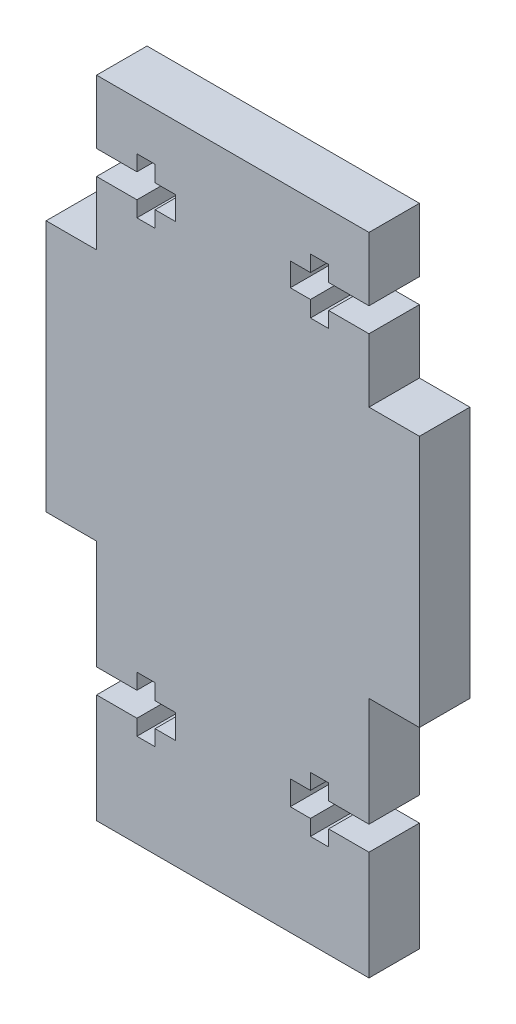
from build123d import *

# Parameters (mm, degrees)
BOSS_EXTRUDE1_DEPTH = 5
CUT_EXTRUDE2_DEPTH  = 6


with BuildPart() as part:
    # Sketch1 → Boss-Extrude1 (new body)
    with BuildSketch(Plane.XY):
        Polygon((-13.5, 0), (13.5, 0), (13.5, 24), (18.5, 24), (18.5, 49), (13.5, 49), (13.5, 64), (-13.5, 64), (-13.5, 49), (-18.5, 49), (-18.5, 24), (-13.5, 24), align=None)
    extrude(amount=BOSS_EXTRUDE1_DEPTH)

    # Sketch2 → Cut-Extrude2 (cut, through all)
    with BuildSketch(Plane.XY.offset(5)):
        Polygon((-13.5, 56.5), (-13.5, 57.7), (-9.5, 57.7), (-9.5, 59.25), (-7.7, 59.25), (-7.7, 57.654169795), (-5.7, 57.654169795), (-5.7, 55.345830205), (-7.7, 55.345830205), (-7.7, 53.75), (-9.5, 53.75), (-9.5, 55.3), (-13.5, 55.3), align=None)
        Polygon((13.5, 56.5), (13.5, 55.3), (9.5, 55.3), (9.5, 53.75), (7.7, 53.75), (7.7, 55.345830205), (5.7, 55.345830205), (5.7, 57.654169795), (7.7, 57.654169795), (7.7, 59.25), (9.5, 59.25), (9.5, 57.7), (13.5, 57.7), align=None)
        Polygon((-13.5, 10.8), (-13.5, 13.2), (-9.5, 13.2), (-9.5, 14.75), (-7.7, 14.75), (-7.7, 13.2), (-5.7, 13.2), (-5.7, 10.8), (-7.7, 10.8), (-7.7, 9.25), (-9.5, 9.25), (-9.5, 10.8), align=None)
        Polygon((13.5, 10.8), (9.5, 10.8), (9.5, 9.25), (7.7, 9.25), (7.7, 10.8), (5.7, 10.8), (5.7, 13.2), (7.7, 13.2), (7.7, 14.75), (9.5, 14.75), (9.5, 13.2), (13.5, 13.2), align=None)
    extrude(amount=-CUT_EXTRUDE2_DEPTH, mode=Mode.SUBTRACT)


solid = part.part
